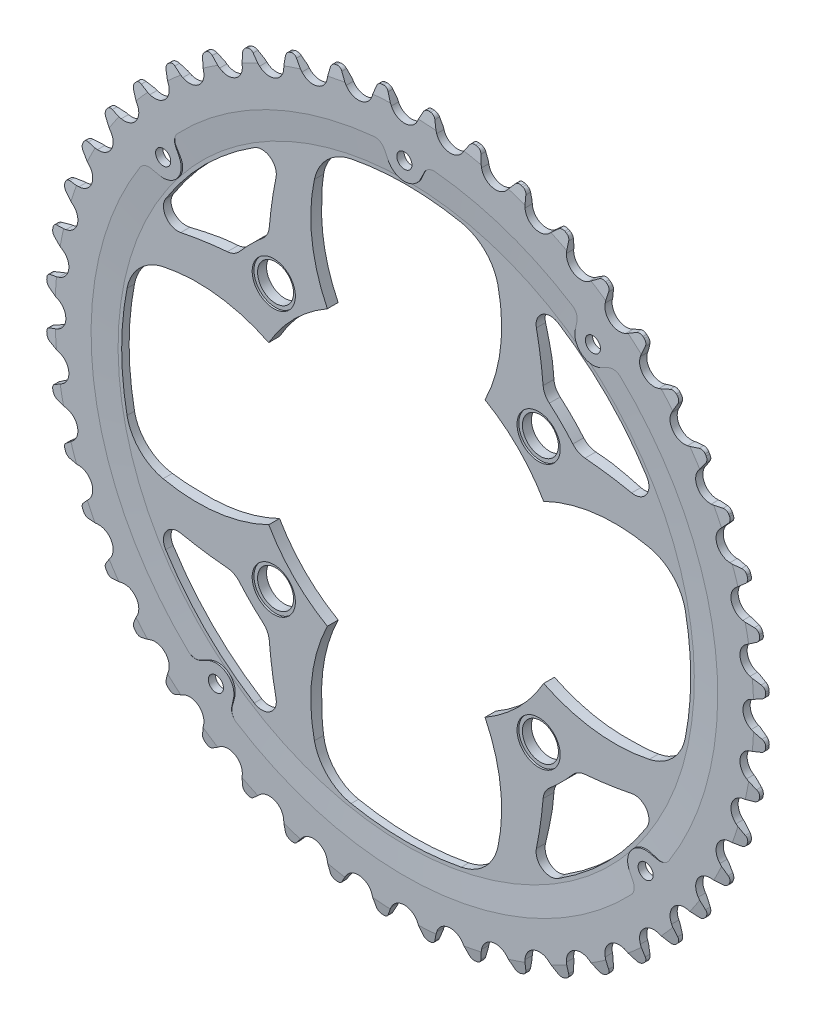
from build123d import *

# Parameters (mm, degrees)
ENL_V_START                  = -3.5
ENL_V_MAT_EXTRU_1_DEPTH      = 5.5
R_P_TITION_CIRCULAIRE1_COUNT = 48
ESQUISSE5_R                  = 5
ENL_V_MAT_EXTRU_2_DEPTH      = 2.0000001
ENL_V_MAT_EXTRU_2_DEPTH_BACK = 3.5
ESQUISSE11_R                 = 6
ENL_V_MAT_EXTRU_7_DEPTH      = 0.5
EXTRUSION1_REACH             = 5.5
ENL_V_MAT_EXTRU_5_DEPTH      = 2.5
ESQUISSE6_R                  = 2.1
ENL_V_MAT_EXTRU_4_DEPTH      = 2.0000001
ENL_V_MAT_EXTRU_4_DEPTH_BACK = 3.5000001
ENL_V_MAT_EXTRU_6_DEPTH      = 10
ENL_V_MAT_EXTRU_8_DEPTH      = 4.0000001


with BuildPart() as part:
    # Esquisse7 → Révolution1 (revolve)
    with BuildSketch(Plane(origin=(0, 0, 0), x_dir=(0, 0, -1), z_dir=(1, 0, 0)), mode=Mode.PRIVATE) as r_volution1_sk:
        Polygon((0, 44), (2.5, 44), (2.5, 66), (1, 87), (1, 100), (-1, 100), (-1, 87), (-0.5, 80), (-0.5, 44), align=None)
    revolve(r_volution1_sk.sketch.rotate(Axis((0, 0, 21.133068783), (0, 0, -1)), 90), axis=Axis((0, 0, 21.133068783), (0, 0, -1)))  # turned: the seam where the file's is

    # Esquisse4 → Enlèvement de matière-Révolution1 (revolve, cut)
    with BuildSketch(Plane(origin=(0, 0, 0), x_dir=(0, 0, -1), z_dir=(1, 0, 0)), mode=Mode.PRIVATE) as enl_vement_de_mati_re_r_volution1_sk:
        Polygon((-1, 100), (-0.5, 100), (-1, 97), align=None)
        Polygon((1, 100), (0.5, 100), (1, 97), align=None)
    revolve(enl_vement_de_mati_re_r_volution1_sk.sketch.rotate(Axis((0, 0, 6.759259259), (0, 0, -1)), 90), axis=Axis((0, 0, 6.759259259), (0, 0, -1)), mode=Mode.SUBTRACT)  # turned: the seam where the file's is

    # Esquisse2 → Enlèv. mat.-Extru.1 (cut)
    with BuildSketch(Plane.XY.offset(ENL_V_START)):
        with BuildLine():
            Line((-4.850886635, 98.937953627), (-3.625231148, 96.309526953))
            ThreePointArc((-3.625231148, 96.309526953), (0, 94), (3.625231148, 96.309526953))
            Line((3.625231148, 96.309526953), (4.850886635, 98.937953627))
            ThreePointArc((4.850886635, 98.937953627), (5.44470111, 99.593903886), (6.304922148, 99.801041862))
            ThreePointArc((6.304922148, 99.801041862), (0, 100), (-6.304922148, 99.801041862))
            ThreePointArc((-6.304922148, 99.801041862), (-5.44470111, 99.593903886), (-4.850886635, 98.937953627))
        make_face()
    enl_v_mat_extru_1 = extrude(amount=ENL_V_MAT_EXTRU_1_DEPTH, mode=Mode.SUBTRACT)

    # Répétition circulaire1: Enlèv. mat.-Extru.1 ×48 about axis
    r_p_tition_circulaire1_axis = Axis((0, 0, 0), (0, 0, 1))
    for i in range(1, R_P_TITION_CIRCULAIRE1_COUNT):
        add(enl_v_mat_extru_1.rotate(r_p_tition_circulaire1_axis, i * 360 / R_P_TITION_CIRCULAIRE1_COUNT), mode=Mode.SUBTRACT)

    # Esquisse5 → Enlèv. mat.-Extru.2 (cut, two sides)
    with BuildSketch(Plane.XY) as enl_v_mat_extru_2_sk:
        with Locations((-36.769552622, 36.769552622)):
            Circle(ESQUISSE5_R)
        with Locations(Location((36.769552622, 36.769552622, 0), (0, 0, 180))):  # turned: the seam where the file's is
            Circle(ESQUISSE5_R)
        with Locations(Location((-36.769552622, -36.769552622, 0), (0, 0, 180))):  # turned: the seam where the file's is
            Circle(ESQUISSE5_R)
        with Locations((36.769552622, -36.769552622)):
            Circle(ESQUISSE5_R)
    extrude(amount=ENL_V_MAT_EXTRU_2_DEPTH, mode=Mode.SUBTRACT)
    extrude(enl_v_mat_extru_2_sk.sketch, amount=-ENL_V_MAT_EXTRU_2_DEPTH_BACK, mode=Mode.SUBTRACT)

    # Esquisse11 → Enlèv. mat.-Extru.7 (cut)
    with BuildSketch(Plane.XY.offset(0.5)):
        with Locations((36.769552622, 36.769552622)):
            Circle(ESQUISSE11_R)
        with Locations((-36.769552622, 36.769552622)):
            Circle(ESQUISSE11_R)
        with Locations((-36.769552622, -36.769552622)):
            Circle(ESQUISSE11_R)
        with Locations((36.769552622, -36.769552622)):
            Circle(ESQUISSE11_R)
    extrude(amount=-ENL_V_MAT_EXTRU_7_DEPTH, mode=Mode.SUBTRACT)

    # Extrusion1: up to this cone (the profile starts inside it)
    extrusion1_end = Plane(origin=(0, 0, 1), z_dir=(0, 0, 1)).offset(-6.214284714) * Cone(1.4e-05, 1389, 99.214284714, align=(Align.CENTER, Align.CENTER, Align.MIN), mode=Mode.PRIVATE)
    # Esquisse8 → Extrusion1 (add, up to the surface)
    with BuildSketch(Plane.XY.offset(1), mode=Mode.PRIVATE) as extrusion1_sk1:
        with BuildLine():
            Line((47.927223734, 70.310386928), (47.440487399, 68.020472511))
            ThreePointArc((47.440487399, 68.020472511), (49.252918026, 63.040860289), (54.523081137, 62.486943825))
            Line((54.523081137, 62.486943825), (56.627223133, 63.513202448))
            ThreePointArc((56.627223133, 63.513202448), (58.401642462, 63.7814515), (60.011705736, 62.988849605))
            ThreePointArc((60.011705736, 62.988849605), (53.562548353, 68.556935564), (46.599665965, 73.467483501))
            ThreePointArc((46.599665965, 73.467483501), (47.758233755, 72.096993739), (47.927223734, 70.310386928))
        make_face()
    extrusion1_tool1 = extrude(extrusion1_sk1.sketch, amount=-EXTRUSION1_REACH, mode=Mode.PRIVATE) & extrusion1_end
    add(extrusion1_tool1.solids().sort_by_distance((51.771738, 66.264802, 1))[0])
    # Esquisse8 → Extrusion1 (add, up to the surface)
    with BuildSketch(Plane.XY.offset(1), mode=Mode.PRIVATE) as extrusion1_sk2:
        with BuildLine():
            Line((-70.310386928, 47.927223734), (-68.020472511, 47.440487399))
            ThreePointArc((-68.020472511, 47.440487399), (-63.040860289, 49.252918026), (-62.486943825, 54.523081137))
            Line((-62.486943825, 54.523081137), (-63.513202448, 56.627223133))
            ThreePointArc((-63.513202448, 56.627223133), (-63.7814515, 58.401642462), (-62.988849605, 60.011705736))
            ThreePointArc((-62.988849605, 60.011705736), (-68.556935564, 53.562548353), (-73.467483501, 46.599665965))
            ThreePointArc((-73.467483501, 46.599665965), (-72.096993739, 47.758233755), (-70.310386928, 47.927223734))
        make_face()
    extrusion1_tool2 = extrude(extrusion1_sk2.sketch, amount=-EXTRUSION1_REACH, mode=Mode.PRIVATE) & extrusion1_end
    add(extrusion1_tool2.solids().sort_by_distance((-66.264802, 51.771738, 1))[0])
    # Esquisse8 → Extrusion1 (add, up to the surface)
    with BuildSketch(Plane.XY.offset(1), mode=Mode.PRIVATE) as extrusion1_sk3:
        with BuildLine():
            Line((-47.927223734, -70.310386928), (-47.440487399, -68.020472511))
            ThreePointArc((-47.440487399, -68.020472511), (-49.252918026, -63.040860289), (-54.523081137, -62.486943825))
            Line((-54.523081137, -62.486943825), (-56.627223133, -63.513202448))
            ThreePointArc((-56.627223133, -63.513202448), (-58.401642462, -63.7814515), (-60.011705736, -62.988849605))
            ThreePointArc((-60.011705736, -62.988849605), (-53.562548353, -68.556935564), (-46.599665965, -73.467483501))
            ThreePointArc((-46.599665965, -73.467483501), (-47.758233755, -72.096993739), (-47.927223734, -70.310386928))
        make_face()
    extrusion1_tool3 = extrude(extrusion1_sk3.sketch, amount=-EXTRUSION1_REACH, mode=Mode.PRIVATE) & extrusion1_end
    add(extrusion1_tool3.solids().sort_by_distance((-51.771738, -66.264802, 1))[0])
    # Esquisse8 → Extrusion1 (add, up to the surface)
    with BuildSketch(Plane.XY.offset(1), mode=Mode.PRIVATE) as extrusion1_sk4:
        with BuildLine():
            Line((70.310386928, -47.927223734), (68.020472511, -47.440487399))
            ThreePointArc((68.020472511, -47.440487399), (63.040860289, -49.252918026), (62.486943825, -54.523081137))
            Line((62.486943825, -54.523081137), (63.513202448, -56.627223133))
            ThreePointArc((63.513202448, -56.627223133), (63.7814515, -58.401642462), (62.988849605, -60.011705736))
            ThreePointArc((62.988849605, -60.011705736), (68.556935564, -53.562548353), (73.467483501, -46.599665965))
            ThreePointArc((73.467483501, -46.599665965), (72.096993739, -47.758233755), (70.310386928, -47.927223734))
        make_face()
    extrusion1_tool4 = extrude(extrusion1_sk4.sketch, amount=-EXTRUSION1_REACH, mode=Mode.PRIVATE) & extrusion1_end
    add(extrusion1_tool4.solids().sort_by_distance((66.264802, -51.771738, 1))[0])
    # Esquisse8 → Extrusion1 (add, up to the surface)
    with BuildSketch(Plane.XY.offset(1), mode=Mode.PRIVATE) as extrusion1_sk5:
        with BuildLine():
            Line((-5.520228854, 84.912286262), (-4.493970231, 82.808144266))
            ThreePointArc((-4.493970231, 82.808144266), (0, 80), (4.493970231, 82.808144266))
            Line((4.493970231, 82.808144266), (5.520228854, 84.912286262))
            ThreePointArc((5.520228854, 84.912286262), (6.75333976, 86.216111022), (8.510061385, 86.582786137))
            ThreePointArc((8.510061385, 86.582786137), (0, 87), (-8.510061385, 86.582786137))
            ThreePointArc((-8.510061385, 86.582786137), (-6.75333976, 86.216111022), (-5.520228854, 84.912286262))
        make_face()
    extrusion1_tool5 = extrude(extrusion1_sk5.sketch, amount=-EXTRUSION1_REACH, mode=Mode.PRIVATE) & extrusion1_end
    add(extrusion1_tool5.solids().sort_by_distance((0, 84.091241, 1))[0])

    # Esquisse9 → Enlèv. mat.-Extru.5 (cut, through all)
    with BuildSketch(Plane(origin=(0, 0, -1), x_dir=(-1, 0, 0), z_dir=(0, 0, -1))):
        with BuildLine():
            Line((-47.440487399, 68.020472511), (-47.927223734, 70.310386928))
            ThreePointArc((-47.927223734, 70.310386928), (-47.758233755, 72.096993739), (-46.599665965, 73.467483501))
            ThreePointArc((-46.599665965, 73.467483501), (-53.562548353, 68.556935564), (-60.011705736, 62.988849605))
            ThreePointArc((-60.011705736, 62.988849605), (-58.401642462, 63.7814515), (-56.627223133, 63.513202448))
            Line((-56.627223133, 63.513202448), (-54.523081137, 62.486943825))
            ThreePointArc((-54.523081137, 62.486943825), (-51.808583086, 62.00830458), (-49.252918026, 63.040860289))
            ThreePointArc((-49.252918026, 63.040860289), (-47.632762299, 65.27081334), (-47.440487399, 68.020472511))
        make_face()
        with BuildLine():
            Line((70.310386928, 47.927223734), (68.020472511, 47.440487399))
            ThreePointArc((68.020472511, 47.440487399), (63.040860289, 49.252918026), (62.486943825, 54.523081137))
            Line((62.486943825, 54.523081137), (63.513202448, 56.627223133))
            ThreePointArc((63.513202448, 56.627223133), (63.7814515, 58.401642462), (62.988849605, 60.011705736))
            ThreePointArc((62.988849605, 60.011705736), (68.556935564, 53.562548353), (73.467483501, 46.599665965))
            ThreePointArc((73.467483501, 46.599665965), (72.096993739, 47.758233755), (70.310386928, 47.927223734))
        make_face()
        with BuildLine():
            Line((54.523081137, -62.486943825), (56.627223133, -63.513202448))
            ThreePointArc((56.627223133, -63.513202448), (58.401642462, -63.7814515), (60.011705736, -62.988849605))
            ThreePointArc((60.011705736, -62.988849605), (53.562548353, -68.556935564), (46.599665965, -73.467483501))
            ThreePointArc((46.599665965, -73.467483501), (47.758233755, -72.096993739), (47.927223734, -70.310386928))
            Line((47.927223734, -70.310386928), (47.440487399, -68.020472511))
            ThreePointArc((47.440487399, -68.020472511), (49.252918026, -63.040860289), (54.523081137, -62.486943825))
        make_face()
        with BuildLine():
            Line((-70.310386928, -47.927223734), (-68.020472511, -47.440487399))
            ThreePointArc((-68.020472511, -47.440487399), (-63.040860289, -49.252918026), (-62.486943825, -54.523081137))
            Line((-62.486943825, -54.523081137), (-63.513202448, -56.627223133))
            ThreePointArc((-63.513202448, -56.627223133), (-63.7814515, -58.401642462), (-62.988849605, -60.011705736))
            ThreePointArc((-62.988849605, -60.011705736), (-68.556935564, -53.562548353), (-73.467483501, -46.599665965))
            ThreePointArc((-73.467483501, -46.599665965), (-72.096993739, -47.758233755), (-70.310386928, -47.927223734))
        make_face()
        with BuildLine():
            Line((-4.493970231, 82.808144266), (-5.520228854, 84.912286262))
            ThreePointArc((-5.520228854, 84.912286262), (-6.75333976, 86.216111022), (-8.510061385, 86.582786137))
            ThreePointArc((-8.510061385, 86.582786137), (0, 87), (8.510061385, 86.582786137))
            ThreePointArc((8.510061385, 86.582786137), (6.75333976, 86.216111022), (5.520228854, 84.912286262))
            Line((5.520228854, 84.912286262), (4.493970231, 82.808144266))
            ThreePointArc((4.493970231, 82.808144266), (0, 80), (-4.493970231, 82.808144266))
        make_face()
    extrude(amount=ENL_V_MAT_EXTRU_5_DEPTH, mode=Mode.SUBTRACT)

    # Esquisse6 → Enlèv. mat.-Extru.4 (cut, two sides)
    with BuildSketch(Plane.XY) as enl_v_mat_extru_4_sk:
        with Locations((52.331225403, 66.980914057)):
            Circle(ESQUISSE6_R)
        with Locations((-66.980914057, 52.331225403)):
            Circle(ESQUISSE6_R)
        with Locations((-52.331225403, -66.980914057)):
            Circle(ESQUISSE6_R)
        with Locations((66.980914057, -52.331225403)):
            Circle(ESQUISSE6_R)
        with Locations((0, 85)):
            Circle(ESQUISSE6_R)
    extrude(amount=ENL_V_MAT_EXTRU_4_DEPTH, mode=Mode.SUBTRACT)
    extrude(enl_v_mat_extru_4_sk.sketch, amount=-ENL_V_MAT_EXTRU_4_DEPTH_BACK, mode=Mode.SUBTRACT)

    # Esquisse10 → Enlèv. mat.-Extru.6 (cut)
    with BuildSketch(Plane.XY.offset(0.5)):
        with BuildLine():
            ThreePointArc((77.504844697, -15.297027438), (79, 0), (77.504844697, 15.297027438))
            ThreePointArc((77.504844697, 15.297027438), (74.024253618, 21.890480874), (67.493429095, 25.487211824))
            ThreePointArc((67.493429095, 25.487211824), (52.526576406, 26.165888933), (38.166441998, 21.893439776))
            ThreePointArc((38.166441998, 21.893439776), (44, 0), (38.166441998, -21.893439776))
            ThreePointArc((38.166441998, -21.893439776), (52.526576406, -26.165888933), (67.493429095, -25.487211824))
            ThreePointArc((67.493429095, -25.487211824), (74.024253618, -21.890480874), (77.504844697, -15.297027438))
        make_face()
        with BuildLine():
            ThreePointArc((-67.493429095, -25.487211824), (-74.024253618, -21.890480874), (-77.504844697, -15.297027438))
            ThreePointArc((-77.504844697, -15.297027438), (-79, 0), (-77.504844697, 15.297027438))
            ThreePointArc((-77.504844697, 15.297027438), (-74.024253618, 21.890480874), (-67.493429095, 25.487211824))
            ThreePointArc((-67.493429095, 25.487211824), (-52.526576406, 26.165888933), (-38.166441998, 21.893439776))
            ThreePointArc((-38.166441998, 21.893439776), (-44, 0), (-38.166441998, -21.893439776))
            ThreePointArc((-38.166441998, -21.893439776), (-52.526576406, -26.165888933), (-67.493429095, -25.487211824))
        make_face()
        with BuildLine():
            ThreePointArc((-15.297027438, -77.504844697), (0, -79), (15.297027438, -77.504844697))
            ThreePointArc((15.297027438, -77.504844697), (21.890480874, -74.024253618), (25.487211824, -67.493429095))
            ThreePointArc((25.487211824, -67.493429095), (26.165888933, -52.526576406), (21.893439776, -38.166441998))
            ThreePointArc((21.893439776, -38.166441998), (0, -44), (-21.893439776, -38.166441998))
            ThreePointArc((-21.893439776, -38.166441998), (-26.165888933, -52.526576406), (-25.487211824, -67.493429095))
            ThreePointArc((-25.487211824, -67.493429095), (-21.890480874, -74.024253618), (-15.297027438, -77.504844697))
        make_face()
        with BuildLine():
            ThreePointArc((-25.487211824, 67.493429095), (-21.890480874, 74.024253618), (-15.297027438, 77.504844697))
            ThreePointArc((-15.297027438, 77.504844697), (0, 79), (15.297027438, 77.504844697))
            ThreePointArc((15.297027438, 77.504844697), (21.890480874, 74.024253618), (25.487211824, 67.493429095))
            ThreePointArc((25.487211824, 67.493429095), (26.165888933, 52.526576406), (21.893439776, 38.166441998))
            ThreePointArc((21.893439776, 38.166441998), (0, 44), (-21.893439776, 38.166441998))
            ThreePointArc((-21.893439776, 38.166441998), (-26.165888933, 52.526576406), (-25.487211824, 67.493429095))
        make_face()
    extrude(amount=-ENL_V_MAT_EXTRU_6_DEPTH, mode=Mode.SUBTRACT)

    # Esquisse12 → Enlèv. mat.-Extru.8 (cut, through all)
    with BuildSketch(Plane.XY.offset(0.5)):
        with BuildLine():
            ThreePointArc((66.782339238, 42.203307524), (55.861435714, 55.861435714), (42.203307524, 66.782339238))
            ThreePointArc((42.203307524, 66.782339238), (37.791281489, 66.690893243), (36.148444831, 62.595112022))
            ThreePointArc((36.148444831, 62.595112022), (37.27524034, 56.1511036), (38.016982715, 49.651508927))
            ThreePointArc((38.016982715, 49.651508927), (38.547367461, 47.794634576), (39.741868966, 46.277249822))
            ThreePointArc((39.741868966, 46.277249822), (43.133513652, 43.133513652), (46.277249822, 39.741868966))
            ThreePointArc((46.277249822, 39.741868966), (47.794634576, 38.547367461), (49.651508927, 38.016982715))
            ThreePointArc((49.651508927, 38.016982715), (56.1511036, 37.27524034), (62.595112022, 36.148444831))
            ThreePointArc((62.595112022, 36.148444831), (66.690893243, 37.791281489), (66.782339238, 42.203307524))
        make_face()
        with BuildLine():
            ThreePointArc((-49.651508927, 38.016982715), (-47.794634576, 38.547367461), (-46.277249822, 39.741868966))
            ThreePointArc((-46.277249822, 39.741868966), (-43.133513652, 43.133513652), (-39.741868966, 46.277249822))
            ThreePointArc((-39.741868966, 46.277249822), (-38.547367461, 47.794634576), (-38.016982715, 49.651508927))
            ThreePointArc((-38.016982715, 49.651508927), (-37.27524034, 56.1511036), (-36.148444831, 62.595112022))
            ThreePointArc((-36.148444831, 62.595112022), (-37.791281489, 66.690893243), (-42.203307524, 66.782339238))
            ThreePointArc((-42.203307524, 66.782339238), (-55.861435714, 55.861435714), (-66.782339238, 42.203307524))
            ThreePointArc((-66.782339238, 42.203307524), (-66.690893243, 37.791281489), (-62.595112022, 36.148444831))
            ThreePointArc((-62.595112022, 36.148444831), (-56.1511036, 37.27524034), (-49.651508927, 38.016982715))
        make_face()
        with BuildLine():
            ThreePointArc((-66.782339238, -42.203307524), (-55.861435714, -55.861435714), (-42.203307524, -66.782339238))
            ThreePointArc((-42.203307524, -66.782339238), (-37.791281489, -66.690893243), (-36.148444831, -62.595112022))
            ThreePointArc((-36.148444831, -62.595112022), (-37.27524034, -56.1511036), (-38.016982715, -49.651508927))
            ThreePointArc((-38.016982715, -49.651508927), (-38.547367461, -47.794634576), (-39.741868966, -46.277249822))
            ThreePointArc((-39.741868966, -46.277249822), (-43.133513652, -43.133513652), (-46.277249822, -39.741868966))
            ThreePointArc((-46.277249822, -39.741868966), (-47.794634576, -38.547367461), (-49.651508927, -38.016982715))
            ThreePointArc((-49.651508927, -38.016982715), (-56.1511036, -37.27524034), (-62.595112022, -36.148444831))
            ThreePointArc((-62.595112022, -36.148444831), (-66.690893243, -37.791281489), (-66.782339238, -42.203307524))
        make_face()
        with BuildLine():
            ThreePointArc((49.651508927, -38.016982715), (47.794634576, -38.547367461), (46.277249822, -39.741868966))
            ThreePointArc((46.277249822, -39.741868966), (43.133513652, -43.133513652), (39.741868966, -46.277249822))
            ThreePointArc((39.741868966, -46.277249822), (38.547367461, -47.794634576), (38.016982715, -49.651508927))
            ThreePointArc((38.016982715, -49.651508927), (37.27524034, -56.1511036), (36.148444831, -62.595112022))
            ThreePointArc((36.148444831, -62.595112022), (37.791281489, -66.690893243), (42.203307524, -66.782339238))
            ThreePointArc((42.203307524, -66.782339238), (55.861435714, -55.861435714), (66.782339238, -42.203307524))
            ThreePointArc((66.782339238, -42.203307524), (66.690893243, -37.791281489), (62.595112022, -36.148444831))
            ThreePointArc((62.595112022, -36.148444831), (56.1511036, -37.27524034), (49.651508927, -38.016982715))
        make_face()
    extrude(amount=-ENL_V_MAT_EXTRU_8_DEPTH, mode=Mode.SUBTRACT)


solid = part.part
